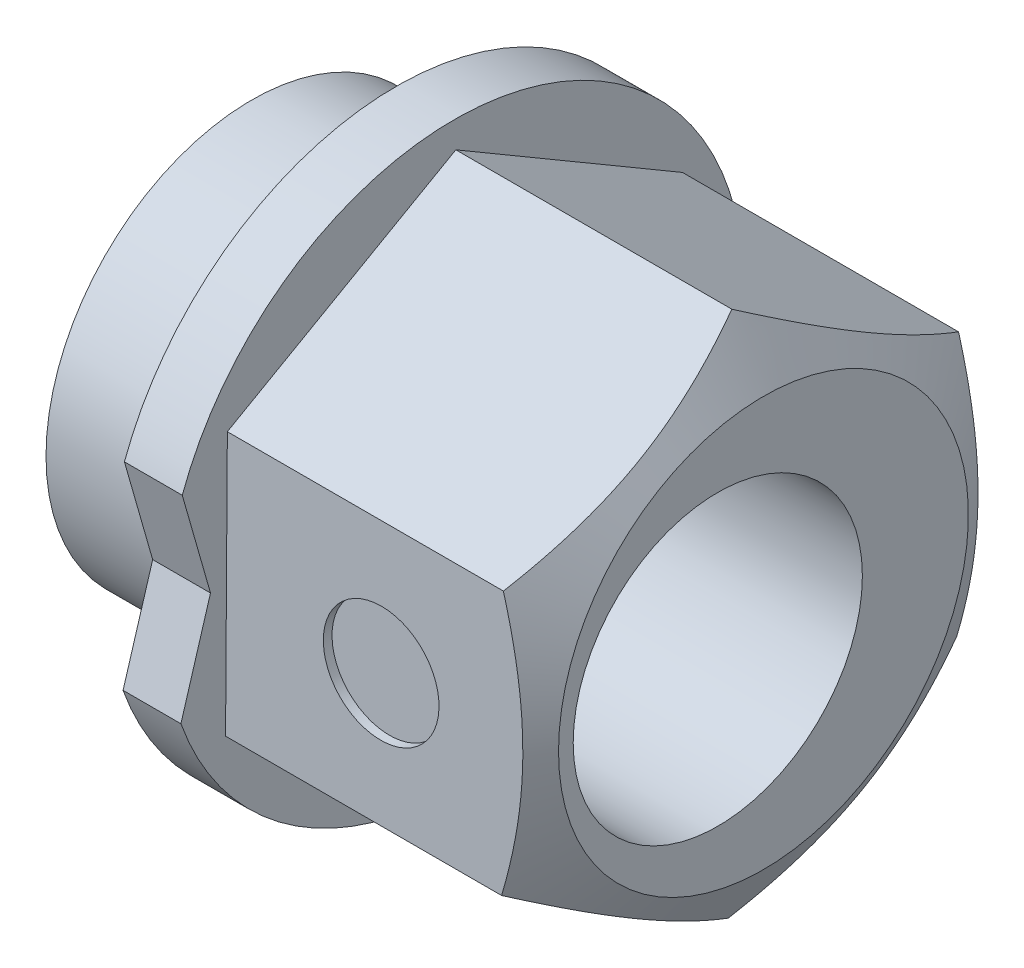
from build123d import *

# Parameters (mm, degrees)
BOSS_EXTRUDE1_DEPTH = 5.35
BOSS_EXTRUDE3_DEPTH = 1
SKETCH4_R           = 3.555
BOSS_EXTRUDE4_DEPTH = 2.5
SKETCH5_R           = 1
CUT_EXTRUDE3_DEPTH  = 0.15
SKETCH3_R           = 2.5
CUT_EXTRUDE5_DEPTH  = 9.85


with BuildPart() as part:
    # Sketch2 → Boss-Extrude1 (new body)
    with BuildSketch(Plane(origin=(0, 0, 0), x_dir=(0, 0, -1), z_dir=(1, 0, 0))):
        Polygon((3.919437566, -2.29861752), (3.950379949, 2.245023741), (0.030942383, 4.54364126), (-3.919437566, 2.29861752), (-3.950379949, -2.245023741), (-0.030942383, -4.54364126), align=None)
    extrude(amount=BOSS_EXTRUDE1_DEPTH)

    # Sketch6 → Boss-Extrude3 (add)
    with BuildSketch(Plane.ZY):
        with BuildLine():
            Line((4.699218, 1.737080939), (4.210840713, 0.028675997))
            Line((4.210840713, 0.028675997), (4.722440239, -1.672919061))
            ThreePointArc((4.722440239, -1.672919061), (-5.009883831, -0.034117514), (4.699218, 1.737080939))
        make_face()
    extrude(amount=BOSS_EXTRUDE3_DEPTH)

    # Sketch4 → Boss-Extrude4 (add)
    with BuildSketch(Plane.ZY.offset(1)):
        Circle(SKETCH4_R)
    extrude(amount=BOSS_EXTRUDE4_DEPTH)

    # Sketch5 → Cut-Extrude3 (cut)
    with BuildSketch(Plane(origin=(0, 0.02679689, 3.934908757), x_dir=(1, 0, 0), z_dir=(0, -0.006809883, -0.999976812))):
        with Locations((2.675, 0)):
            Circle(SKETCH5_R)
    extrude(amount=CUT_EXTRUDE3_DEPTH, mode=Mode.SUBTRACT)

    # Sketch3 → Cut-Extrude5 (cut, through all)
    with BuildSketch(Plane.ZY.offset(3.5)):
        with Locations((0.79, 0)):
            Circle(SKETCH3_R)
    extrude(amount=-CUT_EXTRUDE5_DEPTH, mode=Mode.SUBTRACT)

    # Sketch7 → Cut-Revolve1 (revolve, cut)
    with BuildSketch(Plane.XY):
        Polygon((4.772649731, 4.54364126), (5.35, 3.54364126), (9.772649731, 3.54364126), (9.772649731, 8.54364126), (4.772649731, 8.54364126), align=None)
    revolve(axis=Axis((0, 0, 0), (1, 0, 0)), mode=Mode.SUBTRACT)


solid = part.part
